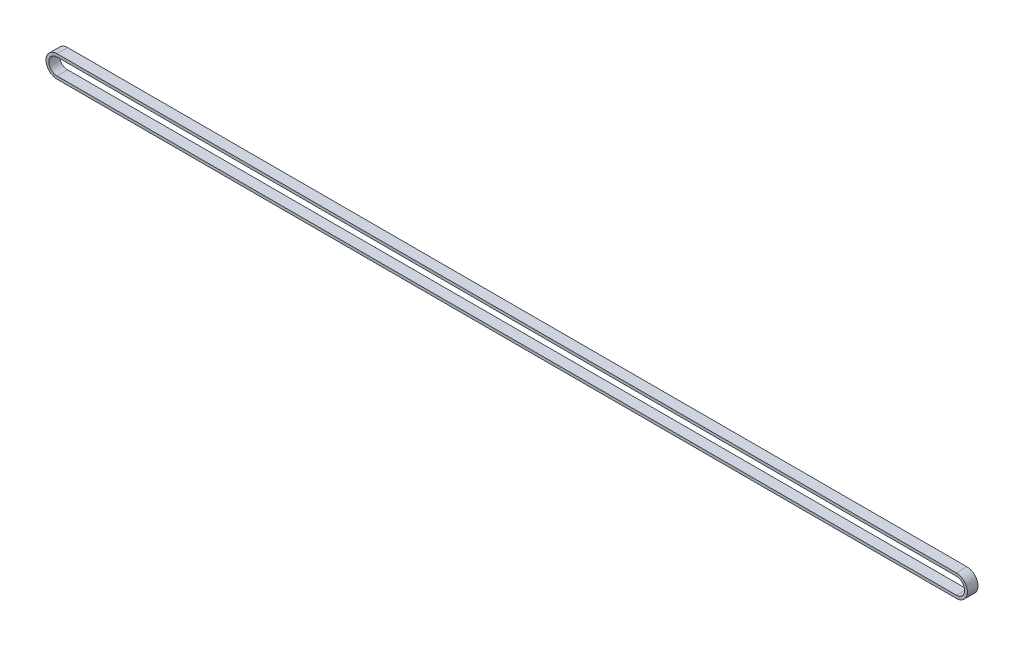
from build123d import *

# Parameters (mm, degrees)
RESSALTO_EXTRUS_O1_DEPTH = 6.25


with BuildPart() as part:
    # Esboço1 → Ressalto-extrusão1 (new body)
    with BuildSketch(Plane.XY.offset(6.25)):
        with BuildLine():
            Line((528.475, 6.5), (0, 6.5))
            ThreePointArc((0, 6.5), (-6.5, 0), (0, -6.5))
            Line((0, -6.5), (528.475, -6.5))
            ThreePointArc((528.475, -6.5), (534.975, 0), (528.475, 6.5))
        make_face()
        with BuildLine():
            Line((0, 4.848), (528.475, 4.848))
            ThreePointArc((528.475, 4.848), (533.323, 0), (528.475, -4.848))
            Line((528.475, -4.848), (0, -4.848))
            ThreePointArc((0, -4.848), (-4.848, 0), (0, 4.848))
        make_face(mode=Mode.SUBTRACT)
    extrude(amount=-RESSALTO_EXTRUS_O1_DEPTH)


solid = part.part
